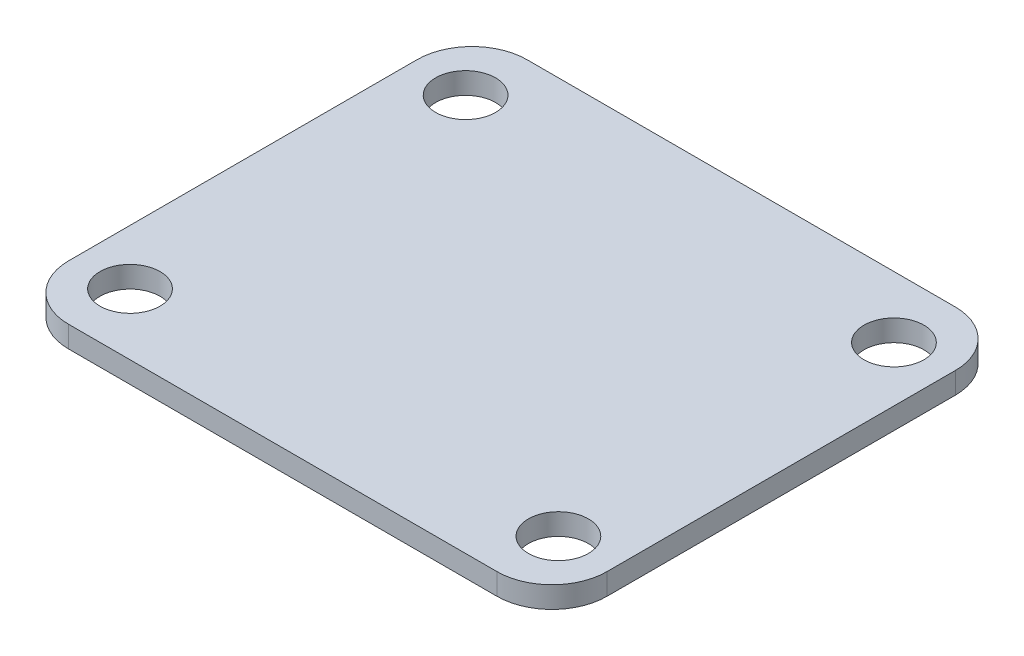
from build123d import *

# Parameters (mm, degrees)
SKETCH1_W           = 37.7
SKETCH1_H           = 32.1
SKETCH1_R           = 2.1
BOSS_EXTRUDE1_DEPTH = 1.5
FILLET1_R           = 3.85


with BuildPart() as part:
    # Sketch1 → Boss-Extrude1 (new body)
    with BuildSketch(Plane(origin=(0, 0, 0), x_dir=(1, 0, 0), z_dir=(0, 1, 0))):
        Rectangle(SKETCH1_W, SKETCH1_H)
        with Locations((15, 11.75)):
            Circle(SKETCH1_R, mode=Mode.SUBTRACT)
        with Locations((15, -11.75)):
            Circle(SKETCH1_R, mode=Mode.SUBTRACT)
        with Locations((-15, 11.75)):
            Circle(SKETCH1_R, mode=Mode.SUBTRACT)
        with Locations((-15, -11.75)):
            Circle(SKETCH1_R, mode=Mode.SUBTRACT)
    extrude(amount=BOSS_EXTRUDE1_DEPTH)

    # Fillet1
    fillet1_edges = [part.edges().sort_by_distance(p)[0] for p in [
        (-18.85, 0.75, -16.05),
        (18.85, 0.75, -16.05),
        (-18.85, 0.75, 16.05),
        (18.85, 0.75, 16.05),
    ]]
    fillet(fillet1_edges, radius=FILLET1_R)

    # Sketch2 → Revolve1 (revolve)
    with BuildSketch(Plane(origin=(0, 0, 0), x_dir=(0, 0, -1), z_dir=(1, 0, 0))):
        Polygon((0, 0), (0, -2.5), (-13.070616019, -2.5), (-16.05, 0), align=None)
    revolve(axis=Axis((0, 0, 0), (0, -1, 0)))


solid = part.part
